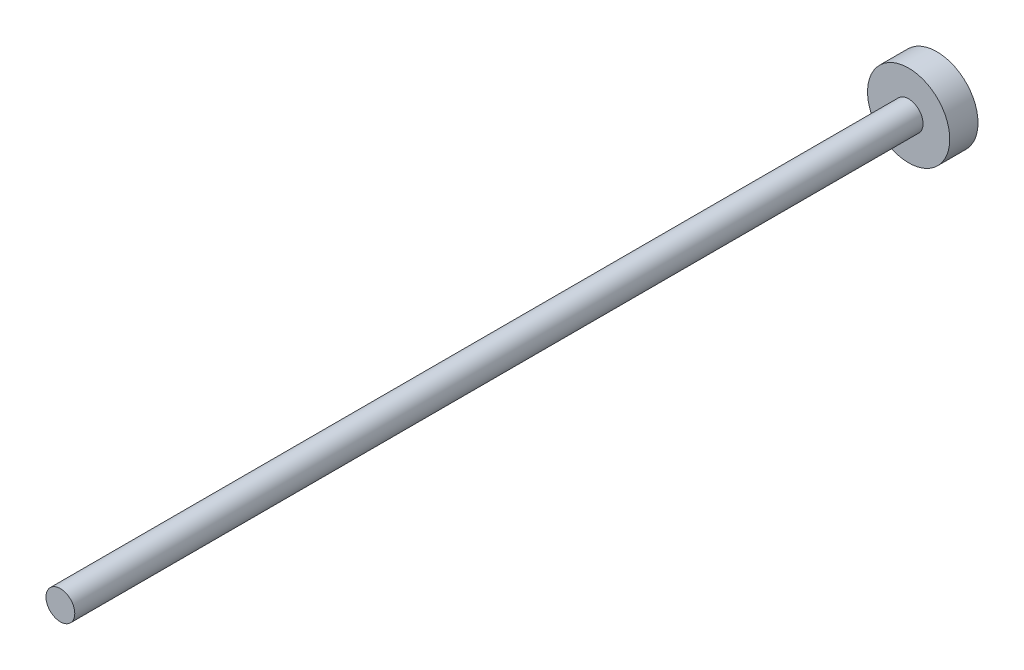
from build123d import *

# Parameters (mm, degrees)
SKETCH1_R           = 4.65
BOSS_EXTRUDE1_DEPTH = 3.2
SKETCH2_R           = 1.63
BOSS_EXTRUDE2_DEPTH = 96


with BuildPart() as part:
    # Sketch1 → Boss-Extrude1 (new body)
    with BuildSketch(Plane.XY):
        Circle(SKETCH1_R)
    extrude(amount=BOSS_EXTRUDE1_DEPTH)

    # Sketch2 → Boss-Extrude2 (add)
    with BuildSketch(Plane.XY.offset(3.2)):
        Circle(SKETCH2_R)
    extrude(amount=BOSS_EXTRUDE2_DEPTH)


solid = part.part
